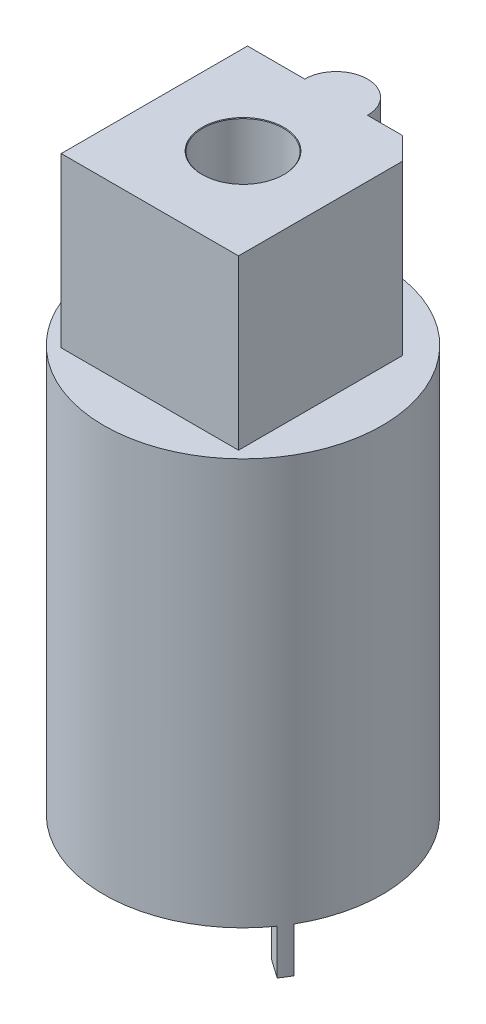
from build123d import *

# Parameters (mm, degrees)
ESBO_O1_R                              = 6.2
RESSALTO_EXTRUS_O1_DEPTH               = 18.1
RESSALTO_EXTRUS_O2_DEPTH               = 2
RESSALTO_EXTRUS_O3_DEPTH               = 7.5
CHANFRO1_SIZE                          = 1
FURO_DE_DI_METRO_3_6_3_6_1_D           = 3.6
FURO_DE_DI_METRO_3_6_3_6_1_DEPTH       = 10
FURO_DE_DI_METRO_3_6_3_6_1_CSINK_D     = 3.65
FURO_DE_DI_METRO_3_6_3_6_1_CSINK_ANGLE = 90
FURO_DE_DI_METRO_3_6_3_6_1_TIP         = 1.081549114


with BuildPart() as part:
    # Esboço1 → Ressalto-extrusão1 (new body)
    with BuildSketch(Plane(origin=(0, 0, 0), x_dir=(1, 0, 0), z_dir=(0, 1, 0))):
        Circle(ESBO_O1_R)
    extrude(amount=RESSALTO_EXTRUS_O1_DEPTH)

    # Esboço2 → Ressalto-extrusão2 (add)
    with BuildSketch(Plane(origin=(0, 0, 0), x_dir=(1, 0, 0), z_dir=(0, 1, 0))):
        with BuildLine():
            Line((4.5033321, -2.6), (5.369357503, -3.1))
            ThreePointArc((5.369357503, -3.1), (5.229026964, -3.331257572), (5.078742675, -3.556173905))
            Line((5.078742675, -3.556173905), (4.25959063, -2.982597469))
            ThreePointArc((4.25959063, -2.982597469), (4.385635518, -2.793957963), (4.5033321, -2.6))
        make_face()
    extrude(amount=-RESSALTO_EXTRUS_O2_DEPTH)

    # Esboço3 → Ressalto-extrusão3 (add)
    with BuildSketch(Plane(origin=(0, 18.1, 0), x_dir=(1, 0, 0), z_dir=(0, 1, 0))):
        with BuildLine():
            Line((1.4, 4.15), (3.95, 4.15))
            Line((3.95, 4.15), (3.95, -4.15))
            Line((3.95, -4.15), (-3.95, -4.15))
            Line((-3.95, -4.15), (-3.95, 4.15))
            Line((-3.95, 4.15), (-1.4, 4.15))
            ThreePointArc((-1.4, 4.15), (0, 5.55), (1.4, 4.15))
        make_face()
    extrude(amount=RESSALTO_EXTRUS_O3_DEPTH)

    # Chanfro1
    chanfro1_edges = [part.edges().sort_by_distance(p)[0] for p in [
        (3.95, 21.85, -4.15),
    ]]
    chamfer(chanfro1_edges, length=CHANFRO1_SIZE)

    # Furo de diâmetro Ø3.6 (3.6)1
    with Locations(Plane(origin=(0, 25.6, 0), x_dir=(1, 0, 0), z_dir=(0, 1, 0))):
        with Locations((0, 0)):
            CounterSinkHole(FURO_DE_DI_METRO_3_6_3_6_1_D / 2, FURO_DE_DI_METRO_3_6_3_6_1_CSINK_D / 2, depth=FURO_DE_DI_METRO_3_6_3_6_1_DEPTH, counter_sink_angle=FURO_DE_DI_METRO_3_6_3_6_1_CSINK_ANGLE)
            with Locations((0, 0, -(FURO_DE_DI_METRO_3_6_3_6_1_DEPTH + FURO_DE_DI_METRO_3_6_3_6_1_TIP / 2))):  # 118° drill point
                Cone(0, FURO_DE_DI_METRO_3_6_3_6_1_D / 2, FURO_DE_DI_METRO_3_6_3_6_1_TIP, mode=Mode.SUBTRACT)


solid = part.part
